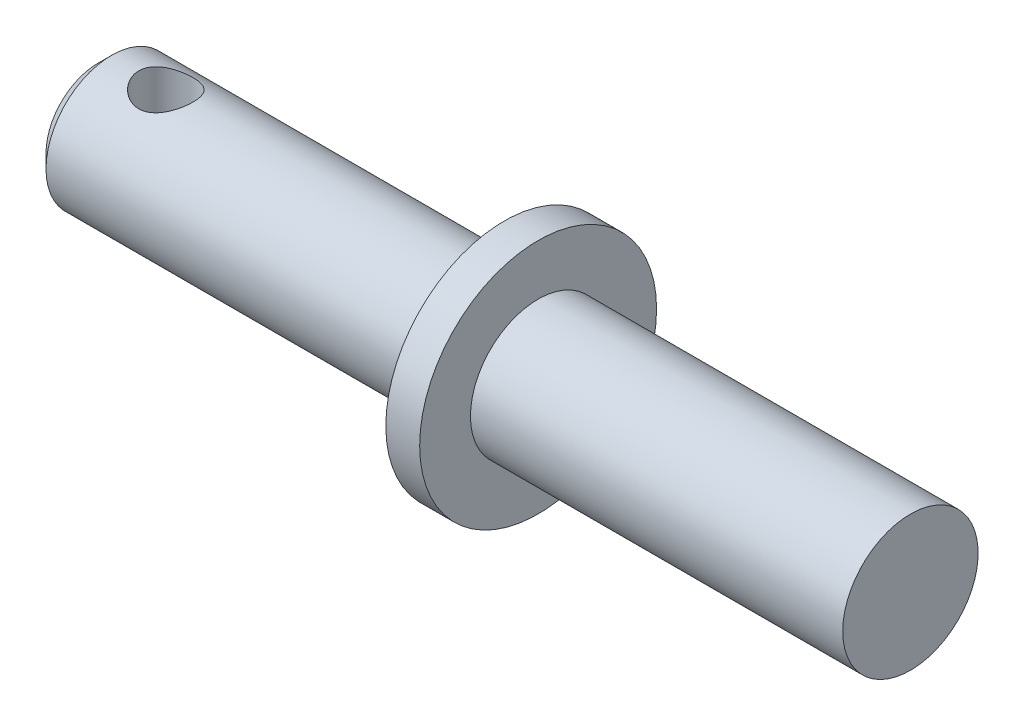
from build123d import *

# Parameters (mm, degrees)
CONG_1_R                     = 2
ESQUISSE2_R                  = 4
ENL_V_MAT_EXTRU_1_DEPTH      = 18.5
ENL_V_MAT_EXTRU_1_DEPTH_BACK = 18.5


with BuildPart() as part:
    # Esquisse1 → Révolution1 (revolve)
    with BuildSketch(Plane.XY, mode=Mode.PRIVATE) as r_volution1_sk:
        Polygon((55, 0), (55, 10), (0, 10), (0, 17.5), (-5, 17.5), (-5, 9.7), (-63, 9.7), (-65, 7.7), (-65, 0), align=None)
    revolve(r_volution1_sk.sketch.rotate(Axis((0, 0, 0), (1, 0, 0)), 90), axis=Axis((0, 0, 0), (1, 0, 0)))  # turned: the seam where the file's is

    # Congé1
    cong_1_edges = [part.edges().sort_by_distance(p)[0] for p in [
        (-5, 0, -9.7),
    ]]
    fillet(cong_1_edges, radius=CONG_1_R)

    # Esquisse2 → Enlèv. mat.-Extru.1 (cut, two sides)
    with BuildSketch(Plane(origin=(0, 0, 0), x_dir=(1, 0, 0), z_dir=(0, 1, 0))) as enl_v_mat_extru_1_sk:
        with Locations(Location((-55, 0, 0), (0, 0, 270))):  # turned: the seam where the file's is
            Circle(ESQUISSE2_R)
    extrude(amount=ENL_V_MAT_EXTRU_1_DEPTH, mode=Mode.SUBTRACT)
    extrude(enl_v_mat_extru_1_sk.sketch, amount=-ENL_V_MAT_EXTRU_1_DEPTH_BACK, mode=Mode.SUBTRACT)


solid = part.part
